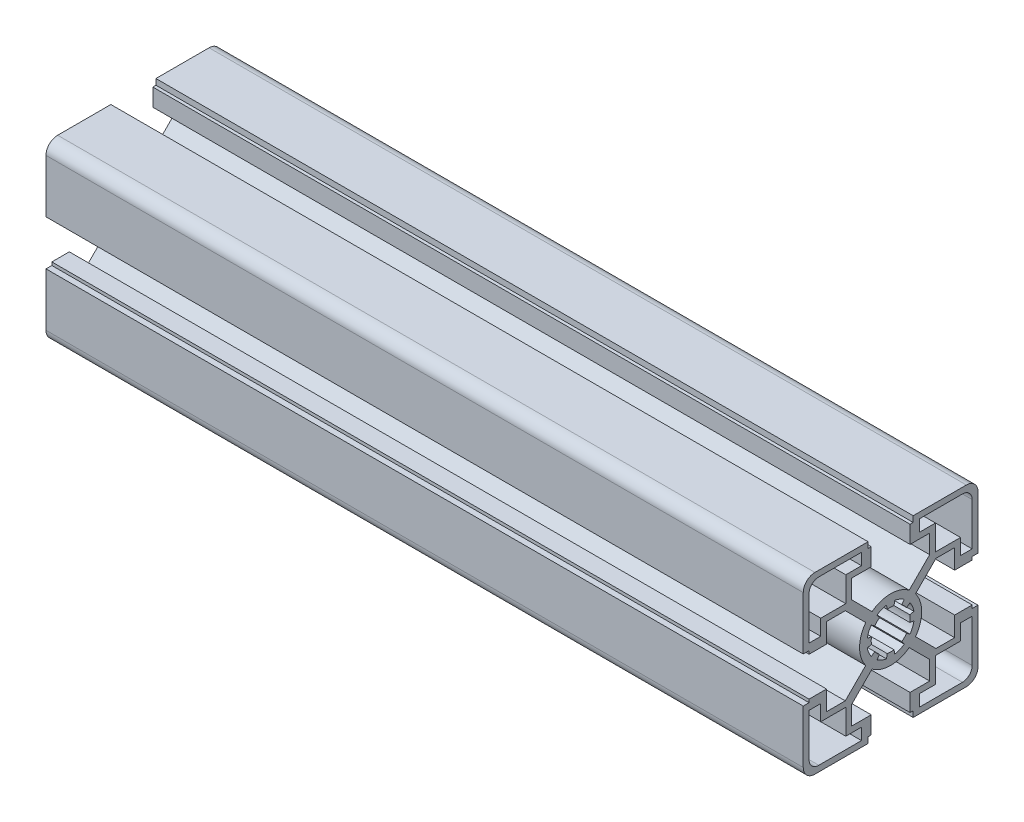
from build123d import *

# Parameters (mm, degrees)
BR_EXTRUDE_DEPTH      = 97.5
BR_EXTRUDE_DEPTH_BACK = 97.5


with BuildPart() as part:
    # Sketch2 → BR_Extrude (new body, two sides)
    with BuildSketch(Plane(origin=(0, 0, 0), x_dir=(0, 0, -1), z_dir=(1, 0, 0))) as br_extrude_sk:
        with BuildLine():
            Line((-10.05, 11.676345597), (-10.05, 16.5))
            Line((-10.05, 16.5), (-5, 16.5))
            Line((-5, 16.5), (-5, 21))
            Line((-5, 21), (-5.8, 21))
            Line((-5.8, 21), (-5.8, 22.5))
            Line((-5.8, 22.5), (-19.5, 22.5))
            ThreePointArc((-19.5, 22.5), (-21.621320344, 21.621320344), (-22.5, 19.5))
            Line((-22.5, 19.5), (-22.5, 5.8))
            Line((-22.5, 5.8), (-21, 5.8))
            Line((-21, 5.8), (-21, 5))
            Line((-21, 5), (-16.5, 5))
            Line((-16.5, 5), (-16.5, 10.05))
            Line((-16.5, 10.05), (-11.676345597, 10.05))
            Line((-11.676345597, 10.05), (-6.411275155, 4.784929559))
            ThreePointArc((-6.411275155, 4.784929559), (-8, 0), (-6.411275155, -4.784929559))
            Line((-6.411275155, -4.784929559), (-11.676345597, -10.05))
            Line((-11.676345597, -10.05), (-16.5, -10.05))
            Line((-16.5, -10.05), (-16.5, -5))
            Line((-16.5, -5), (-21, -5))
            Line((-21, -5), (-21, -5.8))
            Line((-21, -5.8), (-22.5, -5.8))
            Line((-22.5, -5.8), (-22.5, -19.5))
            ThreePointArc((-22.5, -19.5), (-21.621320344, -21.621320344), (-19.5, -22.5))
            Line((-19.5, -22.5), (-5.8, -22.5))
            Line((-5.8, -22.5), (-5.8, -21))
            Line((-5.8, -21), (-5, -21))
            Line((-5, -21), (-5, -16.5))
            Line((-5, -16.5), (-10.05, -16.5))
            Line((-10.05, -16.5), (-10.05, -11.676345597))
            Line((-10.05, -11.676345597), (-4.784929559, -6.411275155))
            ThreePointArc((-4.784929559, -6.411275155), (0, -8), (4.784929559, -6.411275155))
            Line((4.784929559, -6.411275155), (10.05, -11.676345597))
            Line((10.05, -11.676345597), (10.05, -16.5))
            Line((10.05, -16.5), (5, -16.5))
            Line((5, -16.5), (5, -21))
            Line((5, -21), (5.8, -21))
            Line((5.8, -21), (5.8, -22.5))
            Line((5.8, -22.5), (19.5, -22.5))
            ThreePointArc((19.5, -22.5), (21.621320344, -21.621320344), (22.5, -19.5))
            Line((22.5, -19.5), (22.5, -5.8))
            Line((22.5, -5.8), (21, -5.8))
            Line((21, -5.8), (21, -5))
            Line((21, -5), (16.5, -5))
            Line((16.5, -5), (16.5, -10.05))
            Line((16.5, -10.05), (11.676345597, -10.05))
            Line((11.676345597, -10.05), (6.411275155, -4.784929559))
            ThreePointArc((6.411275155, -4.784929559), (8, 0), (6.411275155, 4.784929559))
            Line((6.411275155, 4.784929559), (11.676345597, 10.05))
            Line((11.676345597, 10.05), (16.5, 10.05))
            Line((16.5, 10.05), (16.5, 5))
            Line((16.5, 5), (21, 5))
            Line((21, 5), (21, 5.8))
            Line((21, 5.8), (22.5, 5.8))
            Line((22.5, 5.8), (22.5, 19.5))
            ThreePointArc((22.5, 19.5), (21.621320344, 21.621320344), (19.5, 22.5))
            Line((19.5, 22.5), (5.8, 22.5))
            Line((5.8, 22.5), (5.8, 21))
            Line((5.8, 21), (5, 21))
            Line((5, 21), (5, 16.5))
            Line((5, 16.5), (10.05, 16.5))
            Line((10.05, 16.5), (10.05, 11.676345597))
            Line((10.05, 11.676345597), (4.784929559, 6.411275155))
            ThreePointArc((4.784929559, 6.411275155), (0, 8), (-4.784929559, 6.411275155))
            Line((-4.784929559, 6.411275155), (-10.05, 11.676345597))
        make_face()
        with BuildLine():
            Line((11.55, 11.55), (11.55, 18))
            Line((11.55, 18), (7.5, 18))
            Line((7.5, 18), (7.5, 21))
            Line((7.5, 21), (18.5, 21))
            ThreePointArc((18.5, 21), (20.267766953, 20.267766953), (21, 18.5))
            Line((21, 18.5), (21, 7.5))
            Line((21, 7.5), (18, 7.5))
            Line((18, 7.5), (18, 11.55))
            Line((18, 11.55), (11.55, 11.55))
        make_face(mode=Mode.SUBTRACT)
        with BuildLine():
            Line((11.55, -11.55), (18, -11.55))
            Line((18, -11.55), (18, -7.5))
            Line((18, -7.5), (21, -7.5))
            Line((21, -7.5), (21, -18.5))
            ThreePointArc((21, -18.5), (20.267766953, -20.267766953), (18.5, -21))
            Line((18.5, -21), (7.5, -21))
            Line((7.5, -21), (7.5, -18))
            Line((7.5, -18), (11.55, -18))
            Line((11.55, -18), (11.55, -11.55))
        make_face(mode=Mode.SUBTRACT)
        with BuildLine():
            Line((-11.55, 11.55), (-18, 11.55))
            Line((-18, 11.55), (-18, 7.5))
            Line((-18, 7.5), (-21, 7.5))
            Line((-21, 7.5), (-21, 18.5))
            ThreePointArc((-21, 18.5), (-20.267766953, 20.267766953), (-18.5, 21))
            Line((-18.5, 21), (-7.5, 21))
            Line((-7.5, 21), (-7.5, 18))
            Line((-7.5, 18), (-11.55, 18))
            Line((-11.55, 18), (-11.55, 11.55))
        make_face(mode=Mode.SUBTRACT)
        with BuildLine():
            Line((-11.55, -11.55), (-11.55, -18))
            Line((-11.55, -18), (-7.5, -18))
            Line((-7.5, -18), (-7.5, -21))
            Line((-7.5, -21), (-18.5, -21))
            ThreePointArc((-18.5, -21), (-20.267766953, -20.267766953), (-21, -18.5))
            Line((-21, -18.5), (-21, -7.5))
            Line((-21, -7.5), (-18, -7.5))
            Line((-18, -7.5), (-18, -11.55))
            Line((-18, -11.55), (-11.55, -11.55))
        make_face(mode=Mode.SUBTRACT)
        with BuildLine():
            Line((-6.007327293, -1.059253884), (-4.924038765, -0.868240888))
            ThreePointArc((-4.924038765, -0.868240888), (-5, 0), (-4.924038765, 0.868240888))
            Line((-4.924038765, 0.868240888), (-6.007327293, 1.059253884))
            ThreePointArc((-6.007327293, 1.059253884), (-5.635665148, 2.334368937), (-4.99682747, 3.498816262))
            Line((-4.99682747, 3.498816262), (-4.095760221, 2.867882182))
            ThreePointArc((-4.095760221, 2.867882182), (-3.535533906, 3.535533906), (-2.867882182, 4.095760221))
            Line((-2.867882182, 4.095760221), (-3.498816262, 4.99682747))
            ThreePointArc((-3.498816262, 4.99682747), (-2.334368937, 5.635665148), (-1.059253884, 6.007327293))
            Line((-1.059253884, 6.007327293), (-0.868240888, 4.924038765))
            ThreePointArc((-0.868240888, 4.924038765), (0, 5), (0.868240888, 4.924038765))
            Line((0.868240888, 4.924038765), (1.059253884, 6.007327293))
            ThreePointArc((1.059253884, 6.007327293), (2.334368937, 5.635665148), (3.498816262, 4.99682747))
            Line((3.498816262, 4.99682747), (2.867882182, 4.095760221))
            ThreePointArc((2.867882182, 4.095760221), (3.535533906, 3.535533906), (4.095760221, 2.867882182))
            Line((4.095760221, 2.867882182), (4.99682747, 3.498816262))
            ThreePointArc((4.99682747, 3.498816262), (5.635665148, 2.334368937), (6.007327293, 1.059253884))
            Line((6.007327293, 1.059253884), (4.924038765, 0.868240888))
            ThreePointArc((4.924038765, 0.868240888), (5, 0), (4.924038765, -0.868240888))
            Line((4.924038765, -0.868240888), (6.007327293, -1.059253884))
            ThreePointArc((6.007327293, -1.059253884), (5.635665148, -2.334368937), (4.99682747, -3.498816262))
            Line((4.99682747, -3.498816262), (4.095760221, -2.867882182))
            ThreePointArc((4.095760221, -2.867882182), (3.535533906, -3.535533906), (2.867882182, -4.095760221))
            Line((2.867882182, -4.095760221), (3.498816262, -4.99682747))
            ThreePointArc((3.498816262, -4.99682747), (2.334368937, -5.635665148), (1.059253884, -6.007327293))
            Line((1.059253884, -6.007327293), (0.868240888, -4.924038765))
            ThreePointArc((0.868240888, -4.924038765), (0, -5), (-0.868240888, -4.924038765))
            Line((-0.868240888, -4.924038765), (-1.059253884, -6.007327293))
            ThreePointArc((-1.059253884, -6.007327293), (-2.334368937, -5.635665148), (-3.498816262, -4.99682747))
            Line((-3.498816262, -4.99682747), (-2.867882182, -4.095760221))
            ThreePointArc((-2.867882182, -4.095760221), (-3.535533906, -3.535533906), (-4.095760221, -2.867882182))
            Line((-4.095760221, -2.867882182), (-4.99682747, -3.498816262))
            ThreePointArc((-4.99682747, -3.498816262), (-5.635665148, -2.334368937), (-6.007327293, -1.059253884))
        make_face(mode=Mode.SUBTRACT)
    extrude(amount=BR_EXTRUDE_DEPTH)
    extrude(br_extrude_sk.sketch, amount=-BR_EXTRUDE_DEPTH_BACK)


solid = part.part
